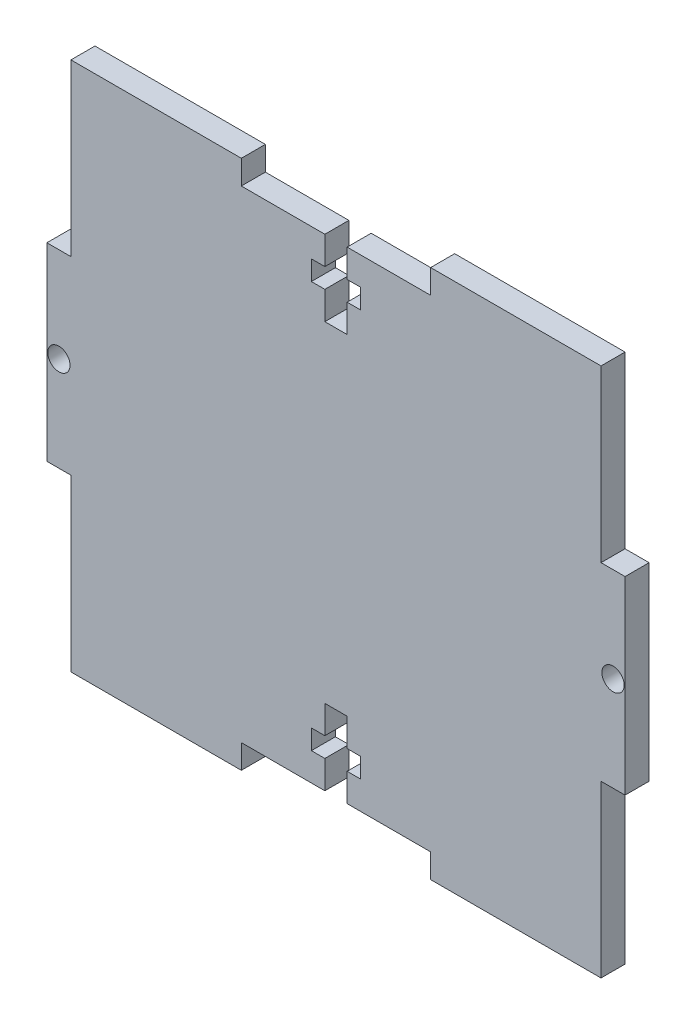
from build123d import *

# Parameters (mm, degrees)
SKETCH1_R           = 1.47
BOSS_EXTRUDE1_DEPTH = 1.5875


with BuildPart() as part:
    # Sketch1 → Boss-Extrude1 (new body, symmetric)
    with BuildSketch(Plane.XY):
        Polygon((-12.5, 35), (-35, 35), (-35, 12.5), (-38.175, 12.5), (-38.175, -12.5), (-35, -12.5), (-35, -35), (-12.5, -35), (-12.5, -31.825), (-1.47, -31.825), (-1.47, -28.125), (-3.25, -28.125), (-3.25, -25.525), (-1.47, -25.525), (-1.47, -21.825), (1.47, -21.825), (1.47, -25.525), (3.25, -25.525), (3.25, -28.125), (1.47, -28.125), (1.47, -31.825), (12.5, -31.825), (12.5, -35), (35, -35), (35, -12.5), (38.175, -12.5), (38.175, 12.5), (35, 12.5), (35, 35), (12.5, 35), (12.5, 31.825), (1.47, 31.825), (1.47, 28.125), (3.25, 28.125), (3.25, 25.525), (1.47, 25.525), (1.47, 21.825), (-1.47, 21.825), (-1.47, 25.525), (-3.25, 25.525), (-3.25, 28.125), (-1.47, 28.125), (-1.47, 31.825), (-12.5, 31.825), align=None)
        with Locations((-36.5875, 0)):
            Circle(SKETCH1_R, mode=Mode.SUBTRACT)
        with Locations((36.5875, 0)):
            Circle(SKETCH1_R, mode=Mode.SUBTRACT)
    extrude(amount=BOSS_EXTRUDE1_DEPTH, both=True)


solid = part.part
